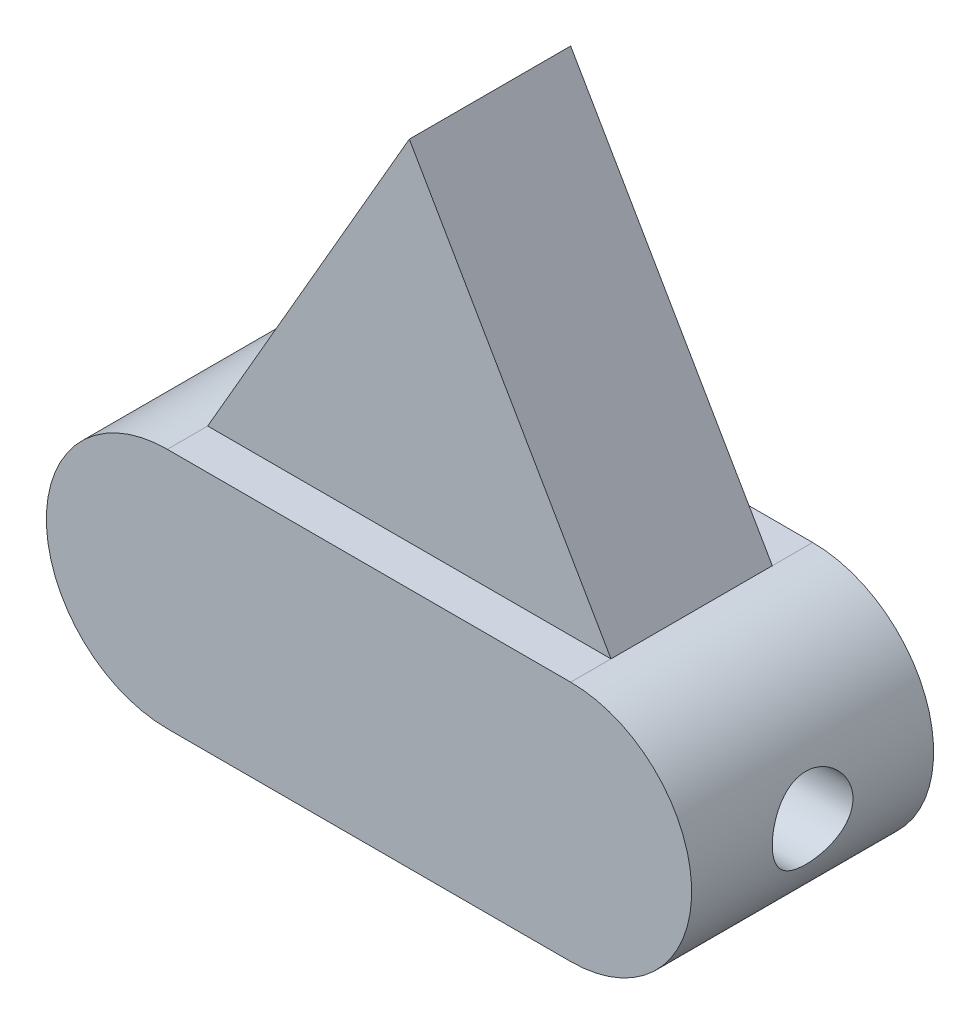
from build123d import *

# Parameters (mm, degrees)
SKETCH3_W               = 127
SKETCH3_H               = 76.2
BOSS_EXTRUDE1_DEPTH     = 76.2
BOSS_EXTRUDE2_DEPTH     = 76.2
BOSS_EXTRUDE3_DEPTH     = 25.4
SKETCH6_R               = 12.7
CUT_EXTRUDE1_DEPTH      = 102.6
CUT_EXTRUDE1_DEPTH_BACK = 102.6


with BuildPart() as part:
    # Sketch3 → Boss-Extrude1 (new body)
    with BuildSketch(Plane(origin=(0, 0, 0), x_dir=(1, 0, 0), z_dir=(0, 1, 0))):
        Rectangle(SKETCH3_W, SKETCH3_H)
    extrude(amount=BOSS_EXTRUDE1_DEPTH)

    # Sketch4 → Boss-Extrude2 (add)
    with BuildSketch(Plane.XY.offset(38.1)):
        with BuildLine():
            Line((-63.5, 76.2), (-63.5, 0))
            ThreePointArc((-63.5, 0), (-101.6, 38.1), (-63.5, 76.2))
        make_face()
        with BuildLine():
            Line((63.5, 76.2), (63.5, 0))
            ThreePointArc((63.5, 0), (101.6, 38.1), (63.5, 76.2))
        make_face()
    extrude(amount=-BOSS_EXTRUDE2_DEPTH)

    # Sketch5 → Boss-Extrude3 (add, symmetric)
    with BuildSketch(Plane.XY):
        Polygon((-63.5, 76.2), (63.5, 76.2), (0, 186.185226281), align=None)
    extrude(amount=BOSS_EXTRUDE3_DEPTH, both=True)

    # Sketch6 → Cut-Extrude1 (cut, two sides)
    with BuildSketch(Plane(origin=(0, 0, 0), x_dir=(0, 0, -1), z_dir=(1, 0, 0))) as cut_extrude1_sk:
        with Locations((0, 38.1)):
            Circle(SKETCH6_R)
    extrude(amount=CUT_EXTRUDE1_DEPTH, mode=Mode.SUBTRACT)
    extrude(cut_extrude1_sk.sketch, amount=-CUT_EXTRUDE1_DEPTH_BACK, mode=Mode.SUBTRACT)


solid = part.part
